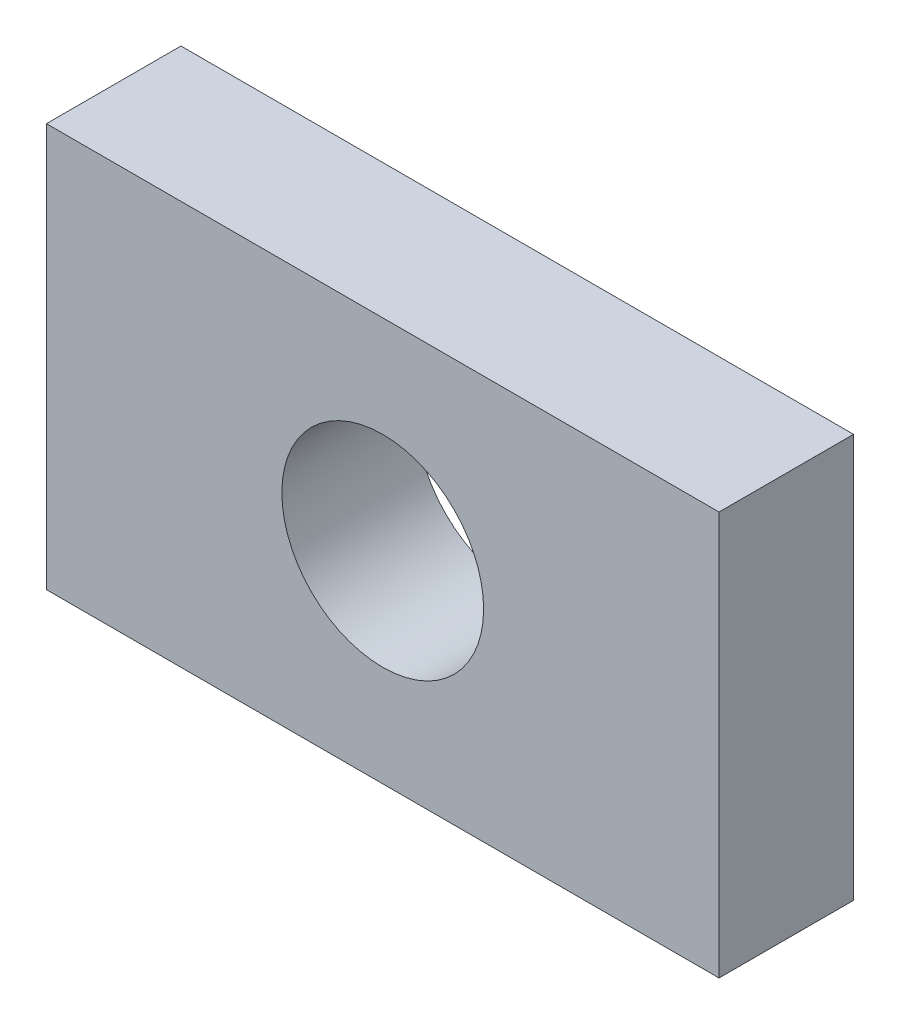
from build123d import *

# Parameters (mm, degrees)
MODEL_W             = 10
MODEL_H             = 6
MODEL_R             = 1.5
BOSS_EXTRUDE1_DEPTH = 2


with BuildPart() as part:
    # Model → Boss-Extrude1 (new body)
    with BuildSketch(Plane.XY):
        Rectangle(MODEL_W, MODEL_H)
        Circle(MODEL_R, mode=Mode.SUBTRACT)
    extrude(amount=BOSS_EXTRUDE1_DEPTH)


solid = part.part
